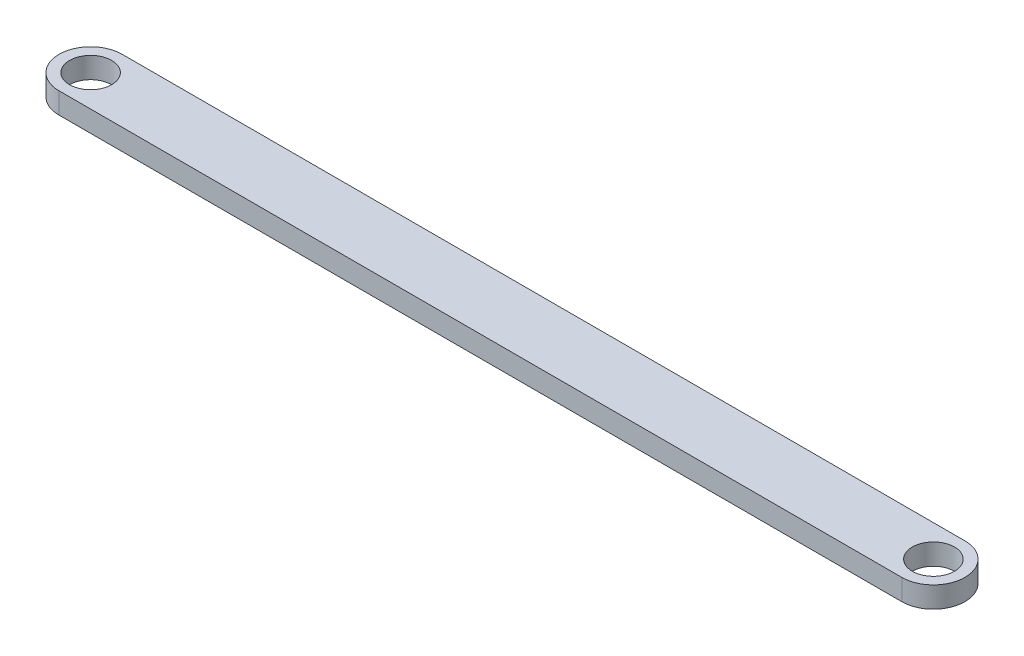
from build123d import *

# Parameters (mm, degrees)
SKETCH2_R           = 10
BOSS_EXTRUDE1_DEPTH = 10


with BuildPart() as part:
    # Sketch2 → Boss-Extrude1 (new body)
    with BuildSketch(Plane(origin=(0, 0, 0), x_dir=(1, 0, 0), z_dir=(0, 1, 0))):
        with BuildLine():
            Line((-208, 15), (192, 15))
            ThreePointArc((192, 15), (207, 0), (192, -15))
            Line((192, -15), (-208, -15))
            ThreePointArc((-208, -15), (-223, 0), (-208, 15))
        make_face()
        with Locations((192, 0)):
            Circle(SKETCH2_R, mode=Mode.SUBTRACT)
        with Locations((-208, 0)):
            Circle(SKETCH2_R, mode=Mode.SUBTRACT)
    extrude(amount=BOSS_EXTRUDE1_DEPTH)


solid = part.part
